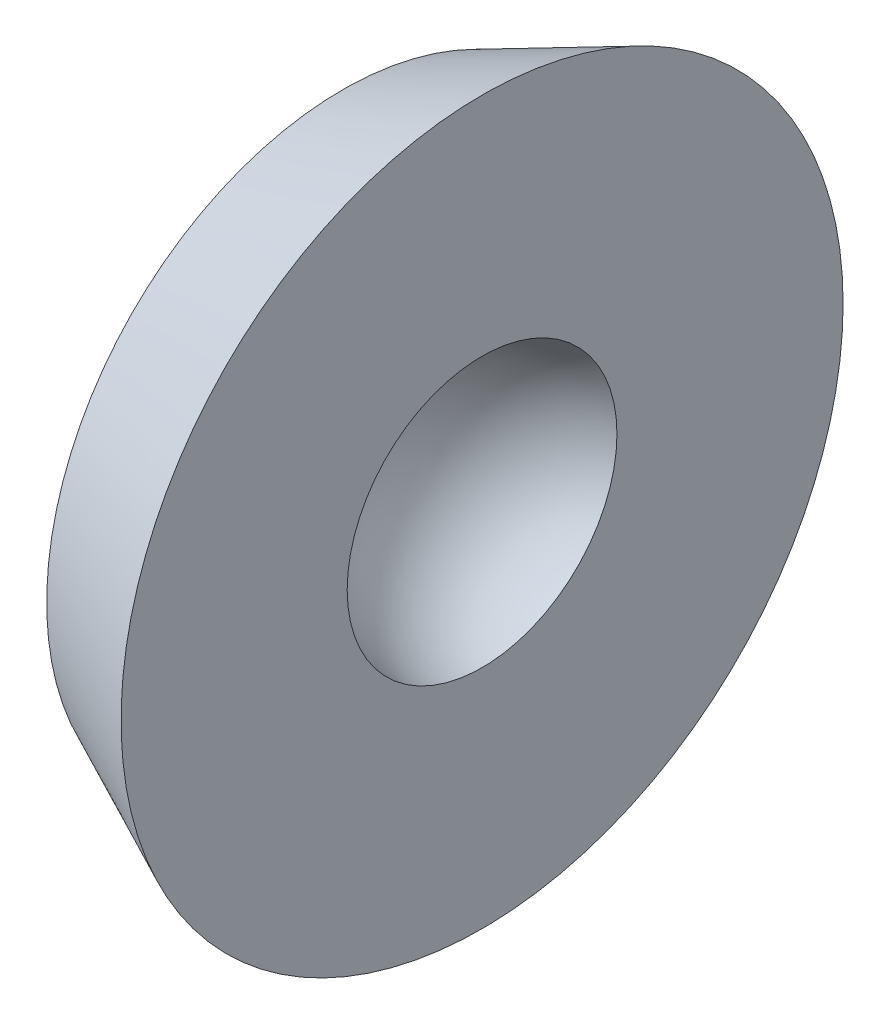
from build123d import *

# Parameters (mm, degrees)
SKETCH1_R           = 4.25
BOSS_EXTRUDE1_DEPTH = 2
BOSS_EXTRUDE1_TAPER = -25


with BuildPart() as part:
    # Sketch1 → Boss-Extrude1 (new body)
    with BuildSketch(Plane(origin=(0, 0, 0), x_dir=(0, 0, -1), z_dir=(1, 0, 0))):
        Circle(SKETCH1_R)
    extrude(amount=BOSS_EXTRUDE1_DEPTH, taper=BOSS_EXTRUDE1_TAPER)

    # Sketch2 → Cut-Revolve1 (revolve, cut)
    with BuildSketch(Plane(origin=(0, 0, 0), x_dir=(1, 0, 0), z_dir=(0, 1, 0))):
        with BuildLine():
            Line((2, 0), (0.5, 0))
            ThreePointArc((0.5, 0), (0.91886117, 1.224744871), (2, 1.936491673))
            Line((2, 1.936491673), (2, 0))
        make_face()
    revolve(axis=Axis((2, 0, 0), (1, 0, 0)), mode=Mode.SUBTRACT)


solid = part.part
